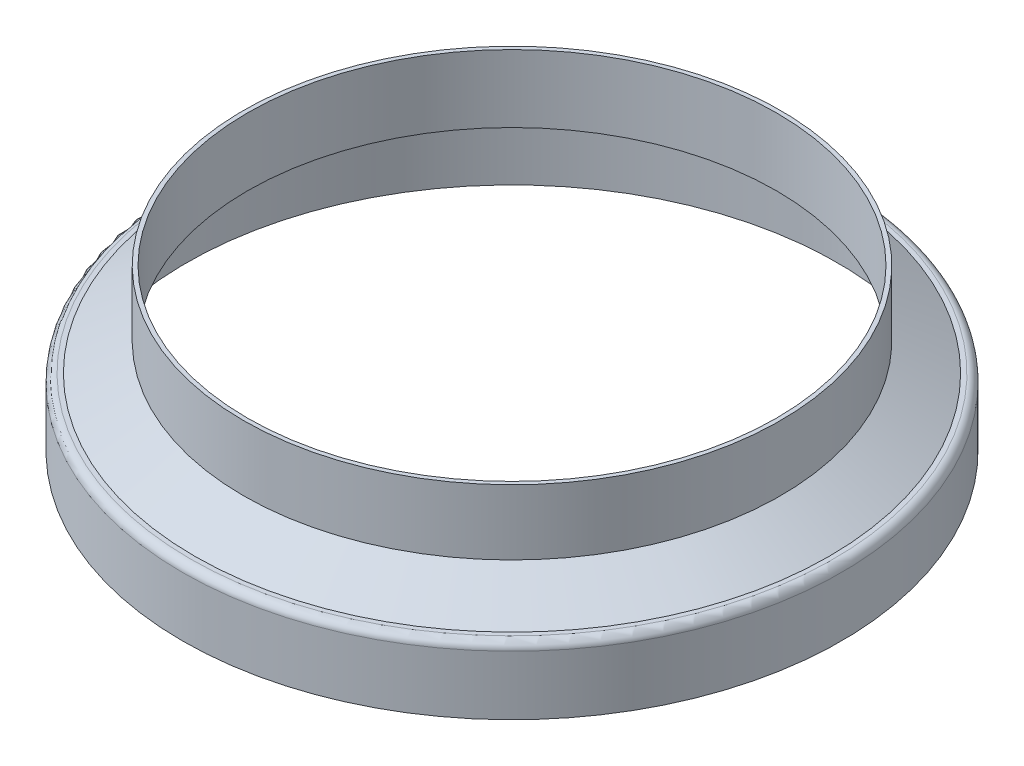
from build123d import *


with BuildPart() as part:
    # Sketch1 → Revolve1 (revolve)
    with BuildSketch(Plane(origin=(0, 0, 0), x_dir=(-1, 0, 0), z_dir=(0, 0, -1))):
        with BuildLine():
            Line((-21.5265, 8.1026), (-18.0086, 10.133660512))
            Line((-18.0086, 10.133660512), (-18.0086, 14.732))
            Line((-18.0086, 14.732), (-18.288, 14.732))
            Line((-18.288, 14.732), (-18.288, 10.294972177))
            Line((-18.288, 10.294972177), (-21.601365004, 8.382))
            Line((-21.601365004, 8.382), (-21.9075, 8.382))
            ThreePointArc((-21.9075, 8.382), (-22.284670757, 8.225770757), (-22.4409, 7.8486))
            Line((-22.4409, 7.8486), (-22.4409, 3.81))
            Line((-22.4409, 3.81), (-22.1615, 3.81))
            Line((-22.1615, 3.81), (-22.1615, 7.8486))
            ThreePointArc((-22.1615, 7.8486), (-22.087105122, 8.028205122), (-21.9075, 8.1026))
            Line((-21.9075, 8.1026), (-21.5265, 8.1026))
        make_face()
    revolve(axis=Axis((0, 3.81, 0), (0, 1, 0)))


solid = part.part
